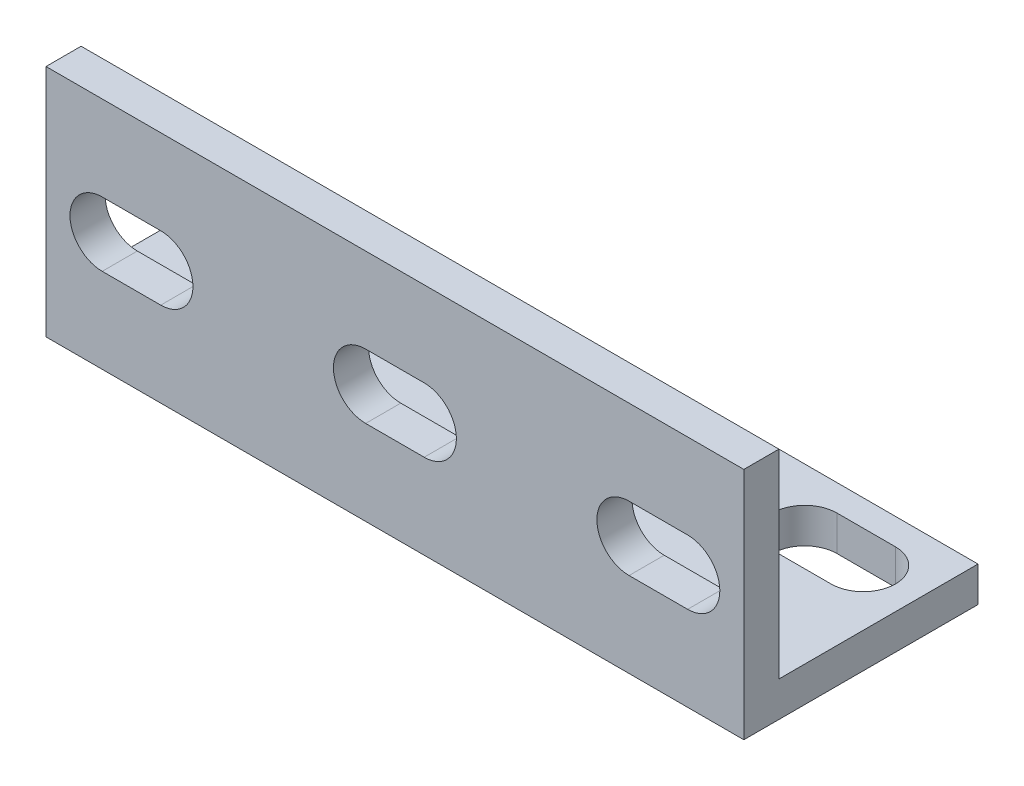
from build123d import *

# Parameters (mm, degrees)
BOSS_EXTRUDE1_DEPTH = 59.6
CUT_EXTRUDE1_DEPTH  = 4
LPATTERN1_COUNT     = 2
LPATTERN1_PITCH     = 22.5
LPATTERN1_COL_COUNT = 2
LPATTERN1_COL_PITCH = 22.5
CUT_EXTRUDE2_DEPTH  = 4
LPATTERN2_COUNT     = 2
LPATTERN2_PITCH     = 22.5
LPATTERN2_COL_COUNT = 2
LPATTERN2_COL_PITCH = 22.5


with BuildPart() as part:
    # Sketch1 → Boss-Extrude1 (new body)
    with BuildSketch(Plane(origin=(0, 0, 0), x_dir=(0, 0, -1), z_dir=(1, 0, 0))):
        Polygon((0, 20), (0, 0), (20, 0), (20, 3), (3, 3), (3, 20), align=None)
    extrude(amount=-BOSS_EXTRUDE1_DEPTH)

    # Sketch2 → Cut-Extrude1 (cut, through all)
    with BuildSketch(Plane(origin=(0, 0, -3), x_dir=(-1, 0, 0), z_dir=(0, 0, -1))):
        with BuildLine():
            Line((27.3, 12.75), (32.3, 12.75))
            ThreePointArc((32.3, 12.75), (35.05, 10), (32.3, 7.25))
            Line((32.3, 7.25), (27.3, 7.25))
            ThreePointArc((27.3, 7.25), (24.55, 10), (27.3, 12.75))
        make_face()
    cut_extrude1 = extrude(amount=-CUT_EXTRUDE1_DEPTH, mode=Mode.SUBTRACT)

    # LPattern1: Cut-Extrude1 ×2
    with Locations(*[(-i * LPATTERN1_PITCH, 0, 0) for i in range(1, LPATTERN1_COUNT)]):
        add(cut_extrude1, mode=Mode.SUBTRACT)

    # LPattern1 col: Cut-Extrude1 ×2
    with Locations(*[(i * LPATTERN1_COL_PITCH, 0, 0) for i in range(1, LPATTERN1_COL_COUNT)]):
        add(cut_extrude1, mode=Mode.SUBTRACT)

    # Sketch3 → Cut-Extrude2 (cut, through all)
    with BuildSketch(Plane(origin=(0, 3, 0), x_dir=(1, 0, 0), z_dir=(0, 1, 0))):
        with BuildLine():
            Line((-27.3, 12.25), (-32.3, 12.25))
            ThreePointArc((-32.3, 12.25), (-35.05, 15), (-32.3, 17.75))
            Line((-32.3, 17.75), (-27.3, 17.75))
            ThreePointArc((-27.3, 17.75), (-24.55, 15), (-27.3, 12.25))
        make_face()
    cut_extrude2 = extrude(amount=-CUT_EXTRUDE2_DEPTH, mode=Mode.SUBTRACT)

    # LPattern2: Cut-Extrude2 ×2
    with Locations(*[(-i * LPATTERN2_PITCH, 0, 0) for i in range(1, LPATTERN2_COUNT)]):
        add(cut_extrude2, mode=Mode.SUBTRACT)

    # LPattern2 col: Cut-Extrude2 ×2
    with Locations(*[(i * LPATTERN2_COL_PITCH, 0, 0) for i in range(1, LPATTERN2_COL_COUNT)]):
        add(cut_extrude2, mode=Mode.SUBTRACT)


solid = part.part
